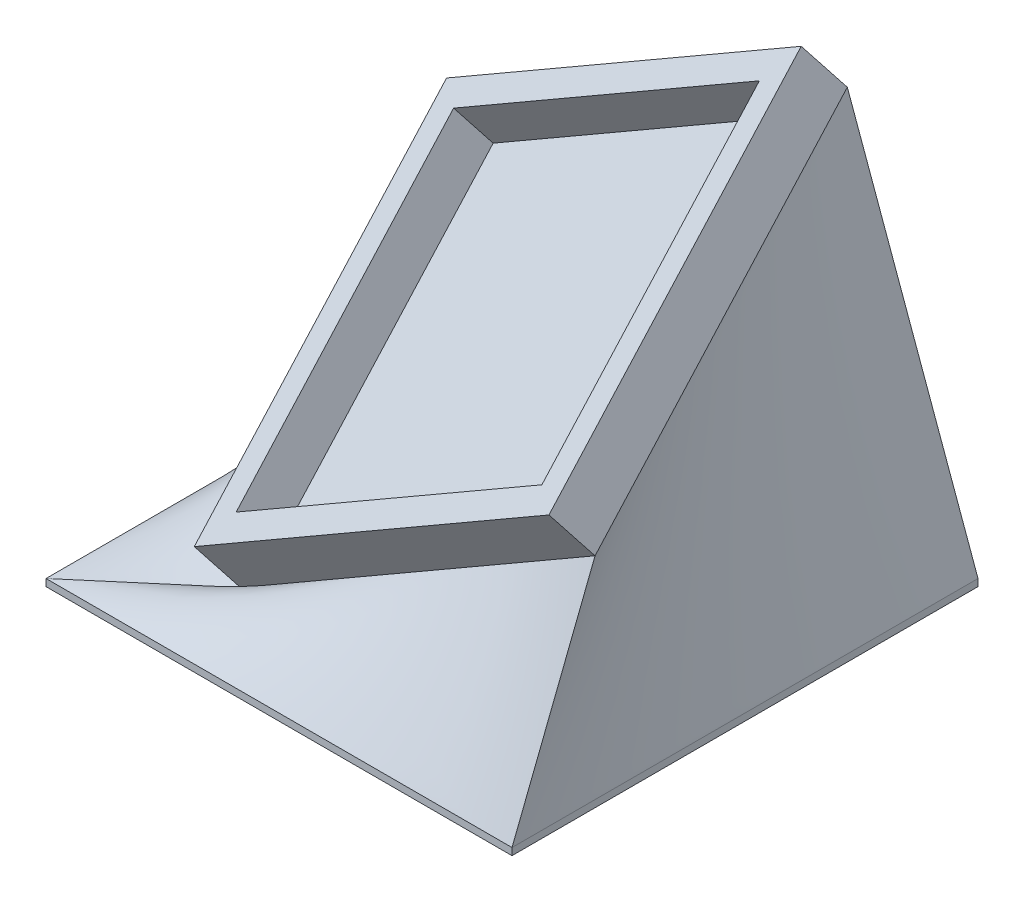
from build123d import *

# Parameters (mm, degrees)
SKETCH1_W             = 36.83
SKETCH1_H             = 36.83
BOSS_EXTRUDE1_DEPTH   = 0.635
SKETCH2_W             = 36.83
SKETCH2_H             = 36.83
SKETCH2_W_2           = 31.75
SKETCH2_H_2           = 31.75
BOSS_EXTRUDE2_DEPTH   = 3.81
SKETCH3_W             = 41.91
SKETCH3_H             = 41.91
BOSS_EXTRUDE3_DEPTH   = 0.635
BODY_MOVE_COPY2_ANGLE = 42.181162358
CUT_EXTRUDE4_DEPTH    = 0.635


with BuildPart() as part:
    # Sketch1 → Boss-Extrude1 (new body)
    with BuildSketch(Plane(origin=(0, 0, 0), x_dir=(1, 0, 0), z_dir=(0, 1, 0))):
        with Locations((-3.873751075, -5.413720286)):
            Rectangle(SKETCH1_W, SKETCH1_H)
    extrude(amount=BOSS_EXTRUDE1_DEPTH)

    # Sketch2 → Boss-Extrude2 (add)
    with BuildSketch(Plane(origin=(0, 0.635, 0), x_dir=(1, 0, 0), z_dir=(0, 1, 0))):
        with Locations((-3.873751075, -5.413720286)):
            Rectangle(SKETCH2_W, SKETCH2_H)
        with Locations((-3.873751075, -5.413720286)):
            Rectangle(SKETCH2_W_2, SKETCH2_H_2, mode=Mode.SUBTRACT)
    extrude(amount=BOSS_EXTRUDE2_DEPTH)


with BuildPart() as part_1:
    # Body-Move/Copy1: moved
    add(part.part.moved(Location((0, 22.86, 0))))


with BuildPart() as body_2:
    # Sketch3 → Boss-Extrude3 (new body)
    with BuildSketch(Plane(origin=(0, 0, 0), x_dir=(1, 0, 0), z_dir=(0, 1, 0))):
        with Locations((-3.873751075, -5.413720286)):
            Rectangle(SKETCH3_W, SKETCH3_H)
    extrude(amount=BOSS_EXTRUDE3_DEPTH)


with BuildPart() as part_2:
    # Body-Move/Copy2: moved
    add(part_1.part.moved(Location((0, 0, 0))).rotate(Axis((-5.232995032, 4.398291679, 4.054476329), (0.6947465906068656, 0.18615678789738588, 0.6947465906068658)), BODY_MOVE_COPY2_ANGLE))


with BuildPart() as part_3:
    # Body-Move/Copy3: moved
    add(part_2.part.moved(Location((8.187497039, 0, -11.563065723))))


    add(body_2.part)  # loft2 joins it to this body
    # loft from a face of the part (loft2)
    loft([part_3.faces().sort_by_distance((-3.522701408, 18.335625, 2.899404563))[0], part_3.faces().sort_by_distance((-3.873751075, 0.635, 5.413720286))[0]])

    # Sketch7 → Cut-Extrude4 (cut)
    with BuildSketch(Plane(origin=(-6.181068967, 10.705925495, -21.411850991), x_dir=(-0.968245836551854, -0.11180339887499008, 0.2236067977499798), z_dir=(-0.250000000000001, 0.43301270189221974, -0.8660254037844383))):
        with BuildLine():
            Line((-12.709591011, 28.05146425), (-13.027900306, 28.207113289))
            add(Edge.make_bspline(
                [(-13.027900306, 28.207113289), (-13.004873845, 28.23475739), (-12.959735292, 28.28894786), (-12.887446549, 28.363622266), (-12.812098651, 28.429545406), (-12.735093224, 28.488179627), (-12.655381337, 28.538055715), (-12.573987538, 28.580539017), (-12.489859194, 28.614381668), (-12.403897368, 28.640064087), (-12.317163559, 28.658547052), (-12.230282789, 28.668284447), (-12.143707378, 28.670451347), (-12.057595409, 28.664825557), (-11.971848743, 28.651556617), (-11.886857584, 28.629315493), (-11.80176719, 28.600229751), (-11.74674571, 28.574765388), (-11.718905914, 28.561880917)],
                knots=[0, 0, 0, 0, 1.169216061, 2.292003209, 3.373957502, 4.420778572, 5.434581096, 6.426691495, 7.401461768, 8.377208393, 9.339675694, 10.280095247, 11.214759555, 12.151120254, 13.081576572, 14.030457123, 15.003449697, 16, 16, 16, 16], degree=3))
            add(Edge.make_bspline(
                [(-11.718905914, 28.561880917), (-11.679316028, 28.540843866), (-11.601131918, 28.499298836), (-11.494301686, 28.421076956), (-11.398990753, 28.330746376), (-11.316272862, 28.229276146), (-11.24588387, 28.120810436), (-11.192405125, 28.006250855), (-11.154161212, 27.888151206), (-11.13516313, 27.767056053), (-11.131759168, 27.646918669), (-11.142428385, 27.530341375), (-11.169702043, 27.418382329), (-11.200200368, 27.348794337), (-11.215500466, 27.313884122)],
                knots=[0, 0, 0, 0, 1.080031914, 2.1329016, 3.181357606, 4.238517395, 5.282830039, 6.291307858, 7.278747883, 8.266429126, 9.236196472, 10.170465502, 11.082177243, 12, 12, 12, 12], degree=3))
            add(Edge.make_bspline(
                [(-11.215500466, 27.313884122), (-11.232855443, 27.281554987), (-11.266793451, 27.218334713), (-11.332056224, 27.133772723), (-11.40659153, 27.059975929), (-11.49228917, 26.998773963), (-11.58781764, 26.949294875), (-11.692785306, 26.910700545), (-11.808006277, 26.883951376), (-11.888445399, 26.875721846), (-11.929943575, 26.87147627)],
                knots=[0, 0, 0, 0, 0.995541569, 1.946801575, 2.889759796, 3.836090081, 4.796084201, 5.804623104, 6.867415087, 8, 8, 8, 8], degree=3))
            add(Edge.make_bspline(
                [(-11.929943575, 26.87147627), (-11.901437214, 26.837570563), (-11.845344793, 26.770853762), (-11.778157897, 26.66014254), (-11.724713416, 26.544564377), (-11.702607795, 26.463342754), (-11.691562164, 26.422758321)],
                knots=[0, 0, 0, 0, 1.03423968, 2.03508997, 3.018183141, 4, 4, 4, 4], degree=3))
            add(Edge.make_bspline(
                [(-11.691562164, 26.422758321), (-11.685505399, 26.393858168), (-11.673607377, 26.337086175), (-11.663645041, 26.25148084), (-11.661662667, 26.167253764), (-11.666544656, 26.084231713), (-11.678355318, 26.002262917), (-11.698206074, 25.921879785), (-11.724716711, 25.842366661), (-11.748319715, 25.791543612), (-11.7602721, 25.765807199)],
                knots=[0, 0, 0, 0, 1.050805723, 2.064222074, 3.062914553, 4.046381319, 5.02179138, 6.006524231, 6.99051873, 8, 8, 8, 8], degree=3))
            add(Edge.make_bspline(
                [(-11.7602721, 25.765807199), (-11.783357357, 25.722734715), (-11.829536346, 25.636573936), (-11.921059874, 25.520868292), (-12.026943018, 25.415902414), (-12.127719546, 25.340316129), (-12.213814814, 25.286429316), (-12.280730825, 25.250441259), (-12.349098519, 25.21959542), (-12.419339911, 25.194420572), (-12.490558955, 25.172950925), (-12.564092334, 25.157991588), (-12.638679825, 25.14634729), (-12.740075119, 25.139244102), (-12.867977423, 25.142024804), (-13.021126946, 25.165457161), (-13.173784475, 25.209019214), (-13.271218324, 25.253176053), (-13.320969216, 25.275723065)],
                knots=[0, 0, 0, 0, 1.28492638, 2.570324455, 3.867386133, 5.203101512, 5.877746533, 6.541435717, 7.20266562, 7.851079607, 8.505513307, 9.15983121, 9.825771498, 10.492365743, 11.83457514, 13.185633051, 14.56295047, 16, 16, 16, 16], degree=3))
            add(Edge.make_bspline(
                [(-13.320969216, 25.275723065), (-13.35351103, 25.29250125), (-13.417643795, 25.325567366), (-13.507177647, 25.383163033), (-13.589308128, 25.445968008), (-13.663398863, 25.513804779), (-13.730441406, 25.586547745), (-13.788279144, 25.665592356), (-13.839961563, 25.748915489), (-13.882761459, 25.837792729), (-13.917294397, 25.931172831), (-13.942357257, 26.028924299), (-13.958866445, 26.130530637), (-13.96441774, 26.235948793), (-13.962824471, 26.345254946), (-13.949912063, 26.458309651), (-13.930365493, 26.575702283), (-13.909407891, 26.65404216), (-13.898693575, 26.694092456)],
                knots=[0, 0, 0, 0, 1.043022444, 2.055568067, 3.029451099, 3.986514844, 4.915347326, 5.843893161, 6.773799783, 7.706255503, 8.650367224, 9.606781734, 10.578110195, 11.579043192, 12.611677261, 13.690045111, 14.819064067, 16, 16, 16, 16], degree=3))
            Line((-13.898693575, 26.694092456), (-13.59230335, 26.544052391))
            add(Edge.make_bspline(
                [(-13.59230335, 26.544052391), (-13.597514002, 26.516291431), (-13.607677344, 26.462143859), (-13.617436272, 26.38252835), (-13.622235893, 26.306922946), (-13.623626876, 26.235705025), (-13.618353523, 26.168460473), (-13.609288009, 26.105471197), (-13.596762335, 26.045928742), (-13.582941327, 26.008959463), (-13.576177549, 25.990867295)],
                knots=[0, 0, 0, 0, 1.208714781, 2.357590318, 3.430168141, 4.450493552, 5.403327119, 6.312913935, 7.174367357, 8, 8, 8, 8], degree=3))
            add(Edge.make_bspline(
                [(-13.576177549, 25.990867295), (-13.566624859, 25.968881104), (-13.547622404, 25.92514561), (-13.510310524, 25.864079335), (-13.468416693, 25.806336941), (-13.420195137, 25.752610056), (-13.365905497, 25.702694145), (-13.305578967, 25.656523463), (-13.239333309, 25.614226645), (-13.192162816, 25.589702815), (-13.168124664, 25.577205436)],
                knots=[0, 0, 0, 0, 0.966660879, 1.922906596, 2.881523, 3.843661356, 4.831814309, 5.854581411, 6.906691573, 8, 8, 8, 8], degree=3))
            add(Edge.make_bspline(
                [(-13.168124664, 25.577205436), (-13.140294061, 25.564294096), (-13.085761087, 25.538994831), (-13.001760874, 25.510621336), (-12.919183761, 25.488918742), (-12.837344424, 25.47711564), (-12.756758588, 25.473347443), (-12.677390283, 25.478553149), (-12.598748341, 25.490851437), (-12.522303405, 25.512777009), (-12.449179558, 25.541652786), (-12.380014213, 25.574903678), (-12.316733778, 25.614696562), (-12.258045148, 25.658724957), (-12.205144949, 25.708850781), (-12.158191528, 25.764522275), (-12.116184167, 25.825274985), (-12.093099129, 25.869081015), (-12.081385882, 25.891308)],
                knots=[0, 0, 0, 0, 1.165600627, 2.283948612, 3.365767746, 4.407471735, 5.421369404, 6.427332593, 7.426484155, 8.441937957, 9.443496595, 10.413093829, 11.354935324, 12.280798633, 13.198439497, 14.118829337, 15.045502359, 16, 16, 16, 16], degree=3))
            add(Edge.make_bspline(
                [(-12.081385882, 25.891308), (-12.067733121, 25.922028132), (-12.040584875, 25.983114502), (-12.018241724, 26.081173486), (-12.008577148, 26.181901415), (-12.014963937, 26.284470122), (-12.033064677, 26.386342837), (-12.066602046, 26.483987329), (-12.113290261, 26.5761807), (-12.164040889, 26.648097271), (-12.213123155, 26.70343625), (-12.256836276, 26.746411323), (-12.307779977, 26.789739894), (-12.365148697, 26.834667692), (-12.430048163, 26.880033714), (-12.50142477, 26.927066942), (-12.579904618, 26.974539383), (-12.634951873, 27.005541411), (-12.663316972, 27.021516334)],
                knots=[0, 0, 0, 0, 1.128253332, 2.243509316, 3.364291053, 4.521414865, 5.688426987, 6.834284024, 7.980221932, 9.153437747, 9.782676484, 10.466312259, 11.213132518, 12.030719459, 12.916108239, 13.875313186, 14.905177875, 16, 16, 16, 16], degree=3))
            Line((-12.663316972, 27.021516334), (-12.522391491, 27.30897627))
            add(Edge.make_bspline(
                [(-12.522391491, 27.30897627), (-12.486966611, 27.292472523), (-12.417468299, 27.260094644), (-12.309274278, 27.226727345), (-12.202358573, 27.201569822), (-12.09637416, 27.191044676), (-11.995303424, 27.19045863), (-11.901866446, 27.201198943), (-11.818100158, 27.223469768), (-11.743884412, 27.25690231), (-11.679029084, 27.299898077), (-11.623268284, 27.351121063), (-11.574907199, 27.408854016), (-11.551309006, 27.452932561), (-11.539418735, 27.475142135)],
                knots=[0, 0, 0, 0, 1.266684072, 2.485044477, 3.666254634, 4.825347396, 5.932569202, 6.94094614, 7.868145919, 8.73365303, 9.570786182, 10.381392303, 11.184442487, 12, 12, 12, 12], degree=3))
            add(Edge.make_bspline(
                [(-11.539418735, 27.475142135), (-11.531514138, 27.492032685), (-11.51582973, 27.525547143), (-11.500037252, 27.578207461), (-11.490038703, 27.631580233), (-11.485952459, 27.685403462), (-11.48716572, 27.740198082), (-11.495259974, 27.795578073), (-11.508520732, 27.851999341), (-11.528081166, 27.908358584), (-11.553429943, 27.963248561), (-11.582537832, 28.016381901), (-11.617973533, 28.065460152), (-11.65808362, 28.111277062), (-11.703221255, 28.153490322), (-11.753260025, 28.192136589), (-11.808276178, 28.22736772), (-11.847511597, 28.247841853), (-11.867543735, 28.25829518)],
                knots=[0, 0, 0, 0, 0.945721101, 1.876512577, 2.781770743, 3.69815765, 4.612083214, 5.558473958, 6.534090419, 7.550970058, 8.581054693, 9.600975577, 10.621655357, 11.647425841, 12.688319064, 13.753940039, 14.853245805, 16, 16, 16, 16], degree=3))
            add(Edge.make_bspline(
                [(-11.867543735, 28.25829518), (-11.900792158, 28.272996751), (-11.965680813, 28.301688792), (-12.068524711, 28.324752645), (-12.17119607, 28.330921294), (-12.256469051, 28.319874538), (-12.324292919, 28.302421624), (-12.376495956, 28.28306152), (-12.429762733, 28.258556049), (-12.48391801, 28.227970451), (-12.539289658, 28.192308294), (-12.595407652, 28.150484366), (-12.652989077, 28.103747535), (-12.690381723, 28.069207896), (-12.709591011, 28.05146425)],
                knots=[0, 0, 0, 0, 1.400069797, 2.732419692, 4.042111645, 5.350902793, 6.031197824, 6.74161272, 7.496220371, 8.29160123, 9.139641393, 10.036123478, 10.991120631, 12, 12, 12, 12], degree=3))
        make_face()
        with BuildLine():
            add(Edge.make_bspline(
                [(-11.150576298, 26.222027006), (-11.125697867, 26.27199575), (-11.077415471, 26.368971749), (-11.001186664, 26.507012247), (-10.926605746, 26.635260468), (-10.850913902, 26.751985412), (-10.775933159, 26.858450471), (-10.70106625, 26.953710314), (-10.626736542, 27.038813785), (-10.551027208, 27.112530254), (-10.475583041, 27.178545069), (-10.399164649, 27.236436003), (-10.322503073, 27.288331489), (-10.244276568, 27.332531133), (-10.165373116, 27.370340509), (-10.085580862, 27.401733454), (-10.004758549, 27.425269179), (-9.923521552, 27.443211819), (-9.842058954, 27.453175709), (-9.761258552, 27.458720617), (-9.681279646, 27.456308671), (-9.602254891, 27.448000889), (-9.524310314, 27.432928552), (-9.446762581, 27.412847235), (-9.370295408, 27.385536519), (-9.320944225, 27.362450639), (-9.29610915, 27.350833096)],
                knots=[0, 0, 0, 0, 1.645622466, 3.193714082, 4.64851321, 6.018943073, 7.294199108, 8.486619125, 9.5899156, 10.62293217, 11.599817348, 12.543876562, 13.447853882, 14.327337271, 15.19033442, 16.025936695, 16.852282149, 17.669963041, 18.475946299, 19.269850328, 20.055668879, 20.831851089, 21.610293465, 22.394176053, 23.191898671, 24, 24, 24, 24], degree=3))
            add(Edge.make_bspline(
                [(-9.29610915, 27.350833096), (-9.271349152, 27.338138877), (-9.222173373, 27.312926917), (-9.152677135, 27.268350098), (-9.087501564, 27.219391584), (-9.026976613, 27.165968888), (-8.970994683, 27.107778119), (-8.919369291, 27.044992658), (-8.872265342, 26.977465352), (-8.830137242, 26.905704836), (-8.792870156, 26.829878477), (-8.761082634, 26.749798374), (-8.736363714, 26.665642404), (-8.716134823, 26.577936424), (-8.703412126, 26.486193616), (-8.695374983, 26.390455401), (-8.69447184, 26.290929875), (-8.698399386, 26.187198406), (-8.709804514, 26.078994034), (-8.728861623, 25.965640743), (-8.756535533, 25.847023346), (-8.792318938, 25.722985065), (-8.837055406, 25.593883165), (-8.888741919, 25.459224832), (-8.949385812, 25.319597749), (-8.994108358, 25.225600573), (-9.017062676, 25.177355532)],
                knots=[0, 0, 0, 0, 0.814165991, 1.617013319, 2.413391986, 3.198612898, 3.977639443, 4.774811213, 5.575761417, 6.385401586, 7.208487704, 8.047011553, 8.90416878, 9.773903233, 10.679547901, 11.613061922, 12.584684085, 13.591255959, 14.650553906, 15.767454708, 16.954095708, 18.214349247, 19.544973591, 20.952775089, 22.43597969, 24, 24, 24, 24], degree=3))
            add(Edge.make_bspline(
                [(-9.017062676, 25.177355532), (-9.040727991, 25.129699556), (-9.08687061, 25.036779962), (-9.16109669, 24.904513163), (-9.234254884, 24.78084479), (-9.308504198, 24.666880586), (-9.384187088, 24.563036911), (-9.460605873, 24.469066677), (-9.537152072, 24.384095302), (-9.615243333, 24.309024734), (-9.693920269, 24.242030547), (-9.773677875, 24.183083621), (-9.85314635, 24.130285338), (-9.934025228, 24.084870926), (-10.015625104, 24.046617324), (-10.097877612, 24.014439965), (-10.181136944, 23.990944035), (-10.264465387, 23.973053185), (-10.34776404, 23.962814776), (-10.43024605, 23.958429939), (-10.511824821, 23.960563828), (-10.59248275, 23.968909545), (-10.672164163, 23.983812423), (-10.75104144, 24.004783505), (-10.828743243, 24.032885747), (-10.879157188, 24.055912354), (-10.904482548, 24.06747973)],
                knots=[0, 0, 0, 0, 1.558593169, 3.03894407, 4.442152743, 5.767690907, 7.022146171, 8.204833714, 9.314809201, 10.370427806, 11.375986558, 12.340035413, 13.274351755, 14.169487474, 15.054669616, 15.912963108, 16.753763908, 17.586328229, 18.407553818, 19.209690951, 20.004194102, 20.795859944, 21.58280399, 22.376687346, 23.18453164, 24, 24, 24, 24], degree=3))
            add(Edge.make_bspline(
                [(-10.904482548, 24.06747973), (-10.92902596, 24.079909038), (-10.977585795, 24.104500775), (-11.04553088, 24.148412388), (-11.109233049, 24.196495816), (-11.168704669, 24.248836709), (-11.22357325, 24.305818846), (-11.273731448, 24.367278639), (-11.319101673, 24.43335495), (-11.360783423, 24.50329562), (-11.396364833, 24.577787737), (-11.426691612, 24.656040131), (-11.451299782, 24.738045214), (-11.469225845, 24.823714576), (-11.48191728, 24.912702977), (-11.489028076, 25.005449238), (-11.48932938, 25.101931375), (-11.484511014, 25.202612181), (-11.472828539, 25.308406226), (-11.450910937, 25.419863787), (-11.422374556, 25.538222255), (-11.384027522, 25.662440269), (-11.338235364, 25.793422036), (-11.284113201, 25.930998714), (-11.221062134, 26.07488542), (-11.1744699, 26.172148297), (-11.150576298, 26.222027006)],
                knots=[0, 0, 0, 0, 0.811786578, 1.606142672, 2.38448377, 3.166669153, 3.942590231, 4.717436731, 5.5060178, 6.307177669, 7.118846937, 7.94022492, 8.782890397, 9.643612447, 10.521857353, 11.435286267, 12.387531091, 13.368541285, 14.410188763, 15.526669534, 16.719915668, 18.00341658, 19.362955021, 20.816004697, 22.367171723, 24, 24, 24, 24], degree=3))
        make_face()
        with BuildLine():
            add(Edge.make_bspline(
                [(-10.858208509, 26.07128582), (-10.87909569, 26.028432551), (-10.919562325, 25.945409013), (-10.973058846, 25.822456054), (-11.021061568, 25.706964725), (-11.062259715, 25.597916751), (-11.095496887, 25.495027869), (-11.123617009, 25.399194756), (-11.143105625, 25.30961587), (-11.156977216, 25.226338491), (-11.163941937, 25.14756945), (-11.165843183, 25.072201811), (-11.164463568, 24.999515444), (-11.156059258, 24.929580525), (-11.144899932, 24.862069673), (-11.126650683, 24.797422688), (-11.105539559, 24.73497216), (-11.069942626, 24.657483703), (-11.017754268, 24.568608452), (-10.941461104, 24.476667693), (-10.854152714, 24.399952002), (-10.787681748, 24.362933964), (-10.754442484, 24.344422839)],
                knots=[0, 0, 0, 0, 1.478520685, 2.864472697, 4.158157987, 5.357847404, 6.478827164, 7.511402538, 8.454140649, 9.320545473, 10.1284481, 10.904400621, 11.658614799, 12.380686544, 13.08742187, 13.778518526, 14.461700067, 15.130028907, 16.42048092, 17.645633705, 18.822682935, 20, 20, 20, 20], degree=3))
            add(Edge.make_bspline(
                [(-10.754442484, 24.344422839), (-10.719358203, 24.329296935), (-10.649374889, 24.299124992), (-10.53572841, 24.277656845), (-10.417971594, 24.273214407), (-10.317675102, 24.286028471), (-10.236320602, 24.304777582), (-10.175444413, 24.326462882), (-10.114574226, 24.352081025), (-10.055233638, 24.384836287), (-9.995966128, 24.422228843), (-9.936906407, 24.464718309), (-9.879611726, 24.514380476), (-9.842368948, 24.549929379), (-9.82335274, 24.568080692)],
                knots=[0, 0, 0, 0, 1.338461443, 2.66985572, 4.033431013, 5.464003699, 6.206675398, 6.962121699, 7.73065642, 8.524041847, 9.339376832, 10.191566911, 11.076611871, 12, 12, 12, 12], degree=3))
            add(Edge.make_bspline(
                [(-9.82335274, 24.568080692), (-9.799949499, 24.591904552), (-9.752274489, 24.640436411), (-9.684678795, 24.719092401), (-9.618501311, 24.803570144), (-9.554241709, 24.894076785), (-9.490970376, 24.990347309), (-9.429236819, 25.092663794), (-9.369808456, 25.201426291), (-9.332108003, 25.276564922), (-9.312936073, 25.314775404)],
                knots=[0, 0, 0, 0, 0.881882224, 1.796492391, 2.737449375, 3.71551771, 4.727364686, 5.779658194, 6.870882666, 8, 8, 8, 8], degree=3))
            add(Edge.make_bspline(
                [(-9.312936073, 25.314775404), (-9.29449075, 25.353470854), (-9.258482043, 25.429011581), (-9.20930814, 25.541448199), (-9.165765693, 25.649835279), (-9.128210542, 25.754512149), (-9.097665743, 25.855800105), (-9.071305368, 25.952877446), (-9.051388256, 26.046475963), (-9.038308359, 26.13646255), (-9.029689984, 26.222564079), (-9.02617242, 26.304951198), (-9.027068347, 26.383462752), (-9.03461242, 26.458091771), (-9.0451373, 26.529310686), (-9.062440622, 26.59638443), (-9.082877011, 26.660142575), (-9.11871013, 26.737362012), (-9.170234601, 26.825617623), (-9.245083467, 26.917322763), (-9.33176155, 26.993100244), (-9.397731783, 27.029662914), (-9.430724535, 27.04794848)],
                knots=[0, 0, 0, 0, 1.331032062, 2.598422548, 3.809916404, 4.957587302, 6.050298616, 7.09415504, 8.080500928, 9.019582027, 9.916437988, 10.766288608, 11.579208551, 12.351872131, 13.093974943, 13.812093626, 14.500558485, 15.169626065, 16.45156004, 17.663227768, 18.831343435, 20, 20, 20, 20], degree=3))
            add(Edge.make_bspline(
                [(-9.430724535, 27.04794848), (-9.465823867, 27.062992704), (-9.536091119, 27.093110549), (-9.650265545, 27.115868171), (-9.769382425, 27.119059376), (-9.870715253, 27.105588184), (-9.953034802, 27.086887803), (-10.014672109, 27.065304838), (-10.075798579, 27.03931204), (-10.136606691, 27.008507248), (-10.196117277, 26.971018061), (-10.254905288, 26.928098842), (-10.313326348, 26.880268079), (-10.37152279, 26.826529062), (-10.429272378, 26.764646196), (-10.488617885, 26.69442167), (-10.547366596, 26.613689142), (-10.60823755, 26.524085038), (-10.669475288, 26.424745308), (-10.731850728, 26.315634265), (-10.79583322, 26.197299652), (-10.836971541, 26.114189857), (-10.858208509, 26.07128582)],
                knots=[0, 0, 0, 0, 1.182112251, 2.366534446, 3.585080437, 4.863823855, 5.526796284, 6.200855057, 6.886281036, 7.586651384, 8.312886817, 9.065530338, 9.843449803, 10.654028886, 11.520795316, 12.467640511, 13.504421541, 14.616422603, 15.827591594, 17.123423383, 18.515015581, 20, 20, 20, 20], degree=3))
        make_face(mode=Mode.SUBTRACT)
        Polygon((-7.240489725, 25.20052739), (-6.883618731, 25.025948063), (-6.69151136, 23.869798223), (-5.659460078, 24.426488928), (-5.301887962, 24.251208479), (-6.631214885, 23.540270979), (-6.335341488, 21.889830274), (-6.696419212, 22.067214088), (-6.929191648, 23.385323063), (-8.101467289, 22.755014569), (-8.456234917, 22.928892774), (-6.985982514, 23.713448063), align=None)
        with BuildLine():
            Line((-3.398374612, 23.395856051), (-3.716683907, 23.55150509))
            add(Edge.make_bspline(
                [(-3.716683907, 23.55150509), (-3.693657446, 23.579149191), (-3.648518893, 23.633339661), (-3.57623015, 23.708014067), (-3.500882253, 23.773937206), (-3.423876825, 23.832571427), (-3.344164938, 23.882447516), (-3.26277114, 23.924930818), (-3.178642795, 23.958773469), (-3.092680969, 23.984455887), (-3.005947161, 24.002938853), (-2.91906639, 24.012676248), (-2.83249098, 24.014843147), (-2.74637901, 24.009217358), (-2.660632344, 23.995948418), (-2.575641185, 23.973707294), (-2.490550791, 23.944621551), (-2.435529312, 23.919157189), (-2.407689516, 23.906272718)],
                knots=[0, 0, 0, 0, 1.169216061, 2.292003209, 3.373957502, 4.420778572, 5.434581096, 6.426691495, 7.401461768, 8.377208393, 9.339675694, 10.280095247, 11.214759555, 12.151120254, 13.081576572, 14.030457123, 15.003449697, 16, 16, 16, 16], degree=3))
            add(Edge.make_bspline(
                [(-2.407689516, 23.906272718), (-2.368099629, 23.885235667), (-2.28991552, 23.843690637), (-2.183085288, 23.765468757), (-2.087774354, 23.675138177), (-2.005056463, 23.573667947), (-1.934667471, 23.465202237), (-1.881188726, 23.350642655), (-1.842944813, 23.232543007), (-1.823946731, 23.111447854), (-1.820542769, 22.991310469), (-1.831211987, 22.874733175), (-1.858485644, 22.76277413), (-1.888983969, 22.693186138), (-1.904284067, 22.658275923)],
                knots=[0, 0, 0, 0, 1.080031914, 2.1329016, 3.181357606, 4.238517395, 5.282830039, 6.291307858, 7.278747883, 8.266429126, 9.236196472, 10.170465502, 11.082177243, 12, 12, 12, 12], degree=3))
            add(Edge.make_bspline(
                [(-1.904284067, 22.658275923), (-1.921639045, 22.625946788), (-1.955577052, 22.562726514), (-2.020839825, 22.478164524), (-2.095375131, 22.404367729), (-2.181072771, 22.343165763), (-2.276601242, 22.293686675), (-2.381568907, 22.255092346), (-2.496789878, 22.228343176), (-2.577229, 22.220113647), (-2.618727176, 22.21586807)],
                knots=[0, 0, 0, 0, 0.995541569, 1.946801575, 2.889759796, 3.836090081, 4.796084201, 5.804623104, 6.867415087, 8, 8, 8, 8], degree=3))
            add(Edge.make_bspline(
                [(-2.618727176, 22.21586807), (-2.590220816, 22.181962364), (-2.534128394, 22.115245563), (-2.466941499, 22.004534341), (-2.413497017, 21.888956178), (-2.391391397, 21.807734554), (-2.380345766, 21.767150122)],
                knots=[0, 0, 0, 0, 1.03423968, 2.03508997, 3.018183141, 4, 4, 4, 4], degree=3))
            add(Edge.make_bspline(
                [(-2.380345766, 21.767150122), (-2.374289, 21.738249968), (-2.362390978, 21.681477976), (-2.352428642, 21.595872641), (-2.350446269, 21.511645565), (-2.355328257, 21.428623514), (-2.36713892, 21.346654717), (-2.386989676, 21.266271585), (-2.413500312, 21.186758461), (-2.437103316, 21.135935413), (-2.449055702, 21.110199)],
                knots=[0, 0, 0, 0, 1.050805723, 2.064222074, 3.062914553, 4.046381319, 5.02179138, 6.006524231, 6.99051873, 8, 8, 8, 8], degree=3))
            add(Edge.make_bspline(
                [(-2.449055702, 21.110199), (-2.472140959, 21.067126516), (-2.518319947, 20.980965737), (-2.609843475, 20.865260092), (-2.715726619, 20.760294214), (-2.816503147, 20.684707929), (-2.902598416, 20.630821117), (-2.969514426, 20.594833059), (-3.03788212, 20.56398722), (-3.108123512, 20.538812373), (-3.179342557, 20.517342726), (-3.252875936, 20.502383389), (-3.327463427, 20.49073909), (-3.42885872, 20.483635903), (-3.556761024, 20.486416604), (-3.709910547, 20.509848961), (-3.862568076, 20.553411015), (-3.960001925, 20.597567854), (-4.009752817, 20.620114865)],
                knots=[0, 0, 0, 0, 1.28492638, 2.570324455, 3.867386133, 5.203101512, 5.877746533, 6.541435717, 7.20266562, 7.851079607, 8.505513307, 9.15983121, 9.825771498, 10.492365743, 11.83457514, 13.185633051, 14.56295047, 16, 16, 16, 16], degree=3))
            add(Edge.make_bspline(
                [(-4.009752817, 20.620114865), (-4.042294631, 20.63689305), (-4.106427396, 20.669959167), (-4.195961248, 20.727554834), (-4.278091729, 20.790359809), (-4.352182464, 20.85819658), (-4.419225007, 20.930939545), (-4.477062745, 21.009984157), (-4.528745165, 21.093307289), (-4.57154506, 21.182184529), (-4.606077998, 21.275564632), (-4.631140859, 21.3733161), (-4.647650046, 21.474922438), (-4.653201341, 21.580340593), (-4.651608073, 21.689646747), (-4.638695665, 21.802701452), (-4.619149095, 21.920094084), (-4.598191492, 21.998433961), (-4.587477176, 22.038484256)],
                knots=[0, 0, 0, 0, 1.043022444, 2.055568067, 3.029451099, 3.986514844, 4.915347326, 5.843893161, 6.773799783, 7.706255503, 8.650367224, 9.606781734, 10.578110195, 11.579043192, 12.611677261, 13.690045111, 14.819064067, 16, 16, 16, 16], degree=3))
            Line((-4.587477176, 22.038484256), (-4.281086952, 21.888444192))
            add(Edge.make_bspline(
                [(-4.281086952, 21.888444192), (-4.286297603, 21.860683232), (-4.296460946, 21.80653566), (-4.306219873, 21.72692015), (-4.311019495, 21.651314747), (-4.312410478, 21.580096826), (-4.307137124, 21.512852274), (-4.29807161, 21.449862998), (-4.285545937, 21.390320543), (-4.271724928, 21.353351264), (-4.26496115, 21.335259096)],
                knots=[0, 0, 0, 0, 1.208714781, 2.357590318, 3.430168141, 4.450493552, 5.403327119, 6.312913935, 7.174367357, 8, 8, 8, 8], degree=3))
            add(Edge.make_bspline(
                [(-4.26496115, 21.335259096), (-4.255408461, 21.313272905), (-4.236406005, 21.269537411), (-4.199094125, 21.208471135), (-4.157200294, 21.150728741), (-4.108978739, 21.097001856), (-4.054689098, 21.047085946), (-3.994362568, 21.000915264), (-3.928116911, 20.958618445), (-3.880946418, 20.934094616), (-3.856908266, 20.921597237)],
                knots=[0, 0, 0, 0, 0.966660879, 1.922906596, 2.881523, 3.843661356, 4.831814309, 5.854581411, 6.906691573, 8, 8, 8, 8], degree=3))
            add(Edge.make_bspline(
                [(-3.856908266, 20.921597237), (-3.829077662, 20.908685896), (-3.774544688, 20.883386632), (-3.690544475, 20.855013137), (-3.607967362, 20.833310542), (-3.526128026, 20.821507441), (-3.44554219, 20.817739244), (-3.366173884, 20.82294495), (-3.287531942, 20.835243237), (-3.211087007, 20.85716881), (-3.137963159, 20.886044586), (-3.068797815, 20.919295479), (-3.00551738, 20.959088362), (-2.946828749, 21.003116758), (-2.89392855, 21.053242582), (-2.84697513, 21.108914075), (-2.804967769, 21.169666786), (-2.78188273, 21.213472816), (-2.770169484, 21.235699801)],
                knots=[0, 0, 0, 0, 1.165600627, 2.283948612, 3.365767746, 4.407471735, 5.421369404, 6.427332593, 7.426484155, 8.441937957, 9.443496595, 10.413093829, 11.354935324, 12.280798633, 13.198439497, 14.118829337, 15.045502359, 16, 16, 16, 16], degree=3))
            add(Edge.make_bspline(
                [(-2.770169484, 21.235699801), (-2.756516722, 21.266419933), (-2.729368477, 21.327506303), (-2.707025325, 21.425565287), (-2.697360749, 21.526293215), (-2.703747539, 21.628861923), (-2.721848278, 21.730734637), (-2.755385647, 21.82837913), (-2.802073863, 21.920572501), (-2.85282449, 21.992489072), (-2.901906756, 22.047828051), (-2.945619878, 22.090803124), (-2.996563579, 22.134131695), (-3.053932299, 22.179059493), (-3.118831765, 22.224425515), (-3.190208372, 22.271458743), (-3.268688219, 22.318931184), (-3.323735474, 22.349933212), (-3.352100574, 22.365908134)],
                knots=[0, 0, 0, 0, 1.128253332, 2.243509316, 3.364291053, 4.521414865, 5.688426987, 6.834284024, 7.980221932, 9.153437747, 9.782676484, 10.466312259, 11.213132518, 12.030719459, 12.916108239, 13.875313186, 14.905177875, 16, 16, 16, 16], degree=3))
            Line((-3.352100574, 22.365908134), (-3.211175093, 22.65336807))
            add(Edge.make_bspline(
                [(-3.211175093, 22.65336807), (-3.175750212, 22.636864324), (-3.1062519, 22.604486444), (-2.99805788, 22.571119146), (-2.891142174, 22.545961623), (-2.785157761, 22.535436476), (-2.684087025, 22.534850431), (-2.590650048, 22.545590744), (-2.506883759, 22.567861568), (-2.432668014, 22.60129411), (-2.367812686, 22.644289878), (-2.312051885, 22.695512864), (-2.2636908, 22.753245817), (-2.240092607, 22.797324361), (-2.228202336, 22.819533936)],
                knots=[0, 0, 0, 0, 1.266684072, 2.485044477, 3.666254634, 4.825347396, 5.932569202, 6.94094614, 7.868145919, 8.73365303, 9.570786182, 10.381392303, 11.184442487, 12, 12, 12, 12], degree=3))
            add(Edge.make_bspline(
                [(-2.228202336, 22.819533936), (-2.220297739, 22.836424486), (-2.204613331, 22.869938944), (-2.188820853, 22.922599262), (-2.178822305, 22.975972034), (-2.17473606, 23.029795263), (-2.175949321, 23.084589882), (-2.184043576, 23.139969874), (-2.197304333, 23.196391141), (-2.216864768, 23.252750385), (-2.242213544, 23.307640362), (-2.271321434, 23.360773702), (-2.306757134, 23.409851952), (-2.346867222, 23.455668863), (-2.392004856, 23.497882123), (-2.442043626, 23.53652839), (-2.497059779, 23.57175952), (-2.536295199, 23.592233654), (-2.556327336, 23.602686981)],
                knots=[0, 0, 0, 0, 0.945721101, 1.876512577, 2.781770743, 3.69815765, 4.612083214, 5.558473958, 6.534090419, 7.550970058, 8.581054693, 9.600975577, 10.621655357, 11.647425841, 12.688319064, 13.753940039, 14.853245805, 16, 16, 16, 16], degree=3))
            add(Edge.make_bspline(
                [(-2.556327336, 23.602686981), (-2.589575759, 23.617388551), (-2.654464414, 23.646080593), (-2.757308312, 23.669144446), (-2.859979671, 23.675313094), (-2.945252652, 23.664266338), (-3.013076521, 23.646813424), (-3.065279558, 23.62745332), (-3.118546335, 23.602947849), (-3.172701611, 23.572362252), (-3.22807326, 23.536700095), (-3.284191253, 23.494876166), (-3.341772678, 23.448139336), (-3.379165324, 23.413599697), (-3.398374612, 23.395856051)],
                knots=[0, 0, 0, 0, 1.400069797, 2.732419692, 4.042111645, 5.350902793, 6.031197824, 6.74161272, 7.496220371, 8.29160123, 9.139641393, 10.036123478, 10.991120631, 12, 12, 12, 12], degree=3))
        make_face()
        with BuildLine():
            add(Edge.make_bspline(
                [(-1.839359899, 21.566418807), (-1.814481468, 21.616387551), (-1.766199073, 21.71336355), (-1.689970265, 21.851404048), (-1.615389347, 21.979652268), (-1.539697503, 22.096377212), (-1.46471676, 22.202842272), (-1.389849851, 22.298102114), (-1.315520144, 22.383205586), (-1.23981081, 22.456922054), (-1.164366642, 22.52293687), (-1.08794825, 22.580827804), (-1.011286674, 22.632723289), (-0.93306017, 22.676922934), (-0.854156717, 22.714732309), (-0.774364464, 22.746125255), (-0.69354215, 22.76966098), (-0.612305154, 22.78760362), (-0.530842556, 22.79756751), (-0.450042154, 22.803112418), (-0.370063247, 22.800700471), (-0.291038492, 22.79239269), (-0.213093915, 22.777320353), (-0.135546182, 22.757239036), (-0.05907901, 22.729928319), (-0.009727826, 22.70684244), (0.015107248, 22.695224897)],
                knots=[0, 0, 0, 0, 1.645622466, 3.193714082, 4.64851321, 6.018943073, 7.294199108, 8.486619125, 9.5899156, 10.62293217, 11.599817348, 12.543876562, 13.447853882, 14.327337271, 15.19033442, 16.025936695, 16.852282149, 17.669963041, 18.475946299, 19.269850328, 20.055668879, 20.831851089, 21.610293465, 22.394176053, 23.191898671, 24, 24, 24, 24], degree=3))
            add(Edge.make_bspline(
                [(0.015107248, 22.695224897), (0.039867247, 22.682530678), (0.089043025, 22.657318718), (0.158539264, 22.612741899), (0.223714835, 22.563783385), (0.284239786, 22.510360689), (0.340221715, 22.45216992), (0.391847107, 22.389384459), (0.438951057, 22.321857152), (0.481079157, 22.250096637), (0.518346243, 22.174270278), (0.550133764, 22.094190175), (0.574852684, 22.010034205), (0.595081576, 21.922328225), (0.607804273, 21.830585417), (0.615841416, 21.734847201), (0.616744559, 21.635321676), (0.612817012, 21.531590206), (0.601411885, 21.423385834), (0.582354775, 21.310032543), (0.554680865, 21.191415147), (0.51889746, 21.067376866), (0.474160993, 20.938274965), (0.42247448, 20.803616633), (0.361830587, 20.66398955), (0.317108041, 20.569992374), (0.294153723, 20.521747332)],
                knots=[0, 0, 0, 0, 0.814165991, 1.617013319, 2.413391986, 3.198612898, 3.977639443, 4.774811213, 5.575761417, 6.385401586, 7.208487704, 8.047011553, 8.90416878, 9.773903233, 10.679547901, 11.613061922, 12.584684085, 13.591255959, 14.650553906, 15.767454708, 16.954095708, 18.214349247, 19.544973591, 20.952775089, 22.43597969, 24, 24, 24, 24], degree=3))
            add(Edge.make_bspline(
                [(0.294153723, 20.521747332), (0.270488407, 20.474091357), (0.224345788, 20.381171762), (0.150119709, 20.248904964), (0.076961515, 20.125236591), (0.0027122, 20.011272386), (-0.072970689, 19.907428712), (-0.149389474, 19.813458478), (-0.225935673, 19.728487103), (-0.304026934, 19.653416535), (-0.38270387, 19.586422348), (-0.462461476, 19.527475422), (-0.541929951, 19.474677138), (-0.622808829, 19.429262726), (-0.704408706, 19.391009125), (-0.786661214, 19.358831766), (-0.869920546, 19.335335836), (-0.953248988, 19.317444985), (-1.036547642, 19.307206577), (-1.119029651, 19.30282174), (-1.200608423, 19.304955628), (-1.281266351, 19.313301345), (-1.360947765, 19.328204223), (-1.439825042, 19.349175305), (-1.517526844, 19.377277547), (-1.567940789, 19.400304154), (-1.593266149, 19.411871531)],
                knots=[0, 0, 0, 0, 1.558593169, 3.03894407, 4.442152743, 5.767690907, 7.022146171, 8.204833714, 9.314809201, 10.370427806, 11.375986558, 12.340035413, 13.274351755, 14.169487474, 15.054669616, 15.912963108, 16.753763908, 17.586328229, 18.407553818, 19.209690951, 20.004194102, 20.795859944, 21.58280399, 22.376687346, 23.18453164, 24, 24, 24, 24], degree=3))
            add(Edge.make_bspline(
                [(-1.593266149, 19.411871531), (-1.617809561, 19.424300839), (-1.666369396, 19.448892576), (-1.734314481, 19.492804189), (-1.79801665, 19.540887617), (-1.857488271, 19.59322851), (-1.912356851, 19.650210647), (-1.962515049, 19.71167044), (-2.007885274, 19.777746751), (-2.049567024, 19.847687421), (-2.085148434, 19.922179537), (-2.115475213, 20.000431932), (-2.140083384, 20.082437015), (-2.158009446, 20.168106377), (-2.170700882, 20.257094778), (-2.177811678, 20.349841039), (-2.178112981, 20.446323176), (-2.173294616, 20.547003982), (-2.16161214, 20.652798026), (-2.139694539, 20.764255588), (-2.111158157, 20.882614055), (-2.072811123, 21.00683207), (-2.027018965, 21.137813837), (-1.972896802, 21.275390514), (-1.909845736, 21.41927722), (-1.863253501, 21.516540097), (-1.839359899, 21.566418807)],
                knots=[0, 0, 0, 0, 0.811786578, 1.606142672, 2.38448377, 3.166669153, 3.942590231, 4.717436731, 5.5060178, 6.307177669, 7.118846937, 7.94022492, 8.782890397, 9.643612447, 10.521857353, 11.435286267, 12.387531091, 13.368541285, 14.410188763, 15.526669534, 16.719915668, 18.00341658, 19.362955021, 20.816004697, 22.367171723, 24, 24, 24, 24], degree=3))
        make_face()
        with BuildLine():
            add(Edge.make_bspline(
                [(-1.546992111, 21.415677621), (-1.567879291, 21.372824352), (-1.608345927, 21.289800814), (-1.661842448, 21.166847855), (-1.70984517, 21.051356526), (-1.751043317, 20.942308552), (-1.784280488, 20.83941967), (-1.812400611, 20.743586557), (-1.831889227, 20.654007671), (-1.845760817, 20.570730292), (-1.852725538, 20.491961251), (-1.854626785, 20.416593612), (-1.853247169, 20.343907245), (-1.844842859, 20.273972326), (-1.833683533, 20.206461473), (-1.815434285, 20.141814488), (-1.794323161, 20.079363961), (-1.758726227, 20.001875504), (-1.70653787, 19.913000253), (-1.630244706, 19.821059494), (-1.542936316, 19.744343802), (-1.476465349, 19.707325765), (-1.443226085, 19.68881464)],
                knots=[0, 0, 0, 0, 1.478520685, 2.864472697, 4.158157987, 5.357847404, 6.478827164, 7.511402538, 8.454140649, 9.320545473, 10.1284481, 10.904400621, 11.658614799, 12.380686544, 13.08742187, 13.778518526, 14.461700067, 15.130028907, 16.42048092, 17.645633705, 18.822682935, 20, 20, 20, 20], degree=3))
            add(Edge.make_bspline(
                [(-1.443226085, 19.68881464), (-1.408141804, 19.673688736), (-1.33815849, 19.643516793), (-1.224512011, 19.622048645), (-1.106755196, 19.617606208), (-1.006458704, 19.630420272), (-0.925104204, 19.649169382), (-0.864228014, 19.670854683), (-0.803357827, 19.696472825), (-0.744017239, 19.729228087), (-0.684749729, 19.766620643), (-0.625690008, 19.80911011), (-0.568395327, 19.858772277), (-0.531152549, 19.89432118), (-0.512136341, 19.912472493)],
                knots=[0, 0, 0, 0, 1.338461443, 2.66985572, 4.033431013, 5.464003699, 6.206675398, 6.962121699, 7.73065642, 8.524041847, 9.339376832, 10.191566911, 11.076611871, 12, 12, 12, 12], degree=3))
            add(Edge.make_bspline(
                [(-0.512136341, 19.912472493), (-0.4887331, 19.936296353), (-0.44105809, 19.984828212), (-0.373462397, 20.063484202), (-0.307284912, 20.147961945), (-0.24302531, 20.238468586), (-0.179753978, 20.33473911), (-0.11802042, 20.437055595), (-0.058592058, 20.545818091), (-0.020891604, 20.620956722), (-0.001719675, 20.659167204)],
                knots=[0, 0, 0, 0, 0.881882224, 1.796492391, 2.737449375, 3.71551771, 4.727364686, 5.779658194, 6.870882666, 8, 8, 8, 8], degree=3))
            add(Edge.make_bspline(
                [(-0.001719675, 20.659167204), (0.016725648, 20.697862654), (0.052734355, 20.773403382), (0.101908258, 20.88584), (0.145450706, 20.994227079), (0.183005857, 21.09890395), (0.213550656, 21.200191906), (0.239911031, 21.297269247), (0.259828143, 21.390867764), (0.27290804, 21.48085435), (0.281526414, 21.56695588), (0.285043978, 21.649342999), (0.284148052, 21.727854552), (0.276603979, 21.802483572), (0.266079099, 21.873702487), (0.248775777, 21.940776231), (0.228339388, 22.004534375), (0.192506268, 22.081753813), (0.140981797, 22.170009424), (0.066132932, 22.261714564), (-0.020545151, 22.337492044), (-0.086515385, 22.374054715), (-0.119508136, 22.392340281)],
                knots=[0, 0, 0, 0, 1.331032062, 2.598422548, 3.809916404, 4.957587302, 6.050298616, 7.09415504, 8.080500928, 9.019582027, 9.916437988, 10.766288608, 11.579208551, 12.351872131, 13.093974943, 13.812093626, 14.500558485, 15.169626065, 16.45156004, 17.663227768, 18.831343435, 20, 20, 20, 20], degree=3))
            add(Edge.make_bspline(
                [(-0.119508136, 22.392340281), (-0.154607469, 22.407384505), (-0.22487472, 22.437502349), (-0.339049146, 22.460259971), (-0.458166027, 22.463451177), (-0.559498854, 22.449979985), (-0.641818403, 22.431279604), (-0.70345571, 22.409696639), (-0.76458218, 22.383703841), (-0.825390293, 22.352899049), (-0.884900879, 22.315409862), (-0.943688889, 22.272490642), (-1.00210995, 22.22465988), (-1.060306391, 22.170920862), (-1.11805598, 22.109037997), (-1.177401487, 22.038813471), (-1.236150197, 21.958080943), (-1.297021151, 21.868476838), (-1.358258889, 21.769137108), (-1.42063433, 21.660026065), (-1.484616821, 21.541691452), (-1.525755142, 21.458581658), (-1.546992111, 21.415677621)],
                knots=[0, 0, 0, 0, 1.182112251, 2.366534446, 3.585080437, 4.863823855, 5.526796284, 6.200855057, 6.886281036, 7.586651384, 8.312886817, 9.065530338, 9.843449803, 10.654028886, 11.520795316, 12.467640511, 13.504421541, 14.616422603, 15.827591594, 17.123423383, 18.515015581, 20, 20, 20, 20], degree=3))
        make_face(mode=Mode.SUBTRACT)
    extrude(amount=-CUT_EXTRUDE4_DEPTH, mode=Mode.SUBTRACT)


solid = part_3.part
